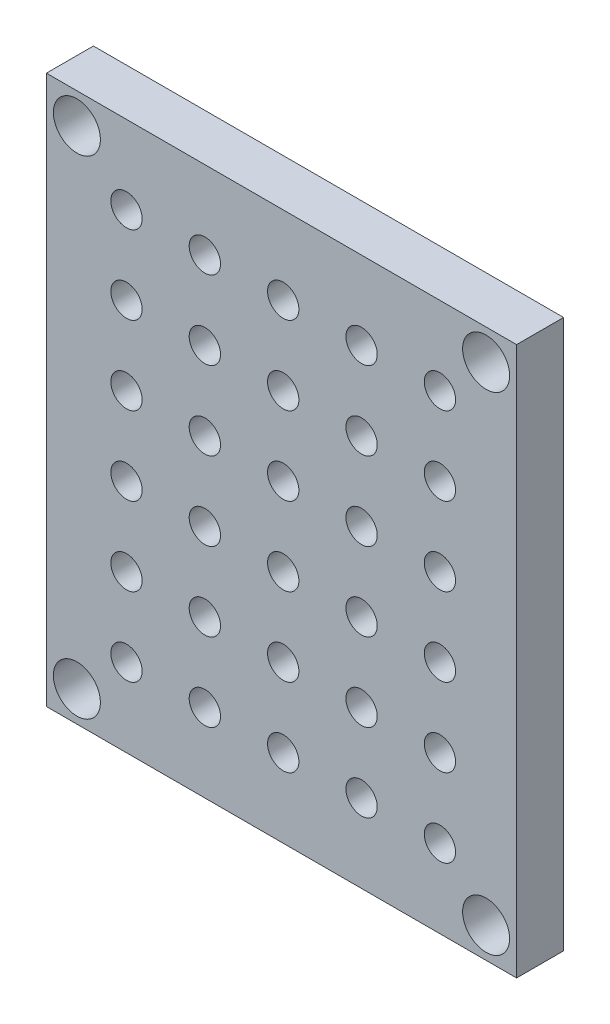
from build123d import *

# Parameters (mm, degrees)
BOSS_EXTRU_4_DEPTH      = 2
ESQUISSE9_W             = 30
ESQUISSE9_H             = 35
BOSS_EXTRU_5_DEPTH      = 3
ESQUISSE7_R             = 1.5
ENL_V_MAT_EXTRU_8_DEPTH = 6
ESQUISSE10_R            = 1
ENL_V_MAT_EXTRU_9_DEPTH = 6


with BuildPart() as part:
    # Esquisse8 → Boss.-Extru.4 (new body)
    with BuildSketch(Plane.XY):
        Polygon((-9.5, 15), (9.5, 15), (12.5, 12), (12.5, -12), (9.5, -15), (-9.5, -15), (-12.5, -12), (-12.5, 12), align=None)
    extrude(amount=-BOSS_EXTRU_4_DEPTH)

    # Esquisse9 → Boss.-Extru.5 (add)
    with BuildSketch(Plane.XY):
        Rectangle(ESQUISSE9_W, ESQUISSE9_H)
    extrude(amount=BOSS_EXTRU_5_DEPTH)

    # Esquisse7 → Enlèv. mat.-Extru.8 (cut, through all)
    with BuildSketch(Plane.XY.offset(3)):
        with Locations((-13.055456352, 15.555456352)):
            Circle(ESQUISSE7_R)
        with Locations((-13.055456352, -15.555456352)):
            Circle(ESQUISSE7_R)
        with Locations((13.055456352, -15.555456352)):
            Circle(ESQUISSE7_R)
        with Locations((13.055456352, 15.555456352)):
            Circle(ESQUISSE7_R)
    extrude(amount=-ENL_V_MAT_EXTRU_8_DEPTH, mode=Mode.SUBTRACT)

    # Esquisse10 → Enlèv. mat.-Extru.9 (cut, through all)
    with BuildSketch(Plane.XY.offset(3)):
        with Locations((-9.890325409, 12.506661491)):
            Circle(ESQUISSE10_R)
        with Locations((-4.890325409, 12.506661491)):
            Circle(ESQUISSE10_R)
        with Locations((0.109674591, 12.506661491)):
            Circle(ESQUISSE10_R)
        with Locations((5.109674591, 12.506661491)):
            Circle(ESQUISSE10_R)
        with Locations((10.109674591, 12.506661491)):
            Circle(ESQUISSE10_R)
        with Locations((-4.890325409, 7.506661491)):
            Circle(ESQUISSE10_R)
        with Locations((0.109674591, 7.506661491)):
            Circle(ESQUISSE10_R)
        with Locations((5.109674591, 7.506661491)):
            Circle(ESQUISSE10_R)
        with Locations((10.109674591, 7.506661491)):
            Circle(ESQUISSE10_R)
        with Locations((-4.890325409, 2.506661491)):
            Circle(ESQUISSE10_R)
        with Locations((0.109674591, 2.506661491)):
            Circle(ESQUISSE10_R)
        with Locations((5.109674591, 2.506661491)):
            Circle(ESQUISSE10_R)
        with Locations((10.109674591, 2.506661491)):
            Circle(ESQUISSE10_R)
        with Locations((-4.890325409, -2.493338509)):
            Circle(ESQUISSE10_R)
        with Locations((0.109674591, -2.493338509)):
            Circle(ESQUISSE10_R)
        with Locations((5.109674591, -2.493338509)):
            Circle(ESQUISSE10_R)
        with Locations((10.109674591, -2.493338509)):
            Circle(ESQUISSE10_R)
        with Locations((-4.890325409, -7.493338509)):
            Circle(ESQUISSE10_R)
        with Locations((0.109674591, -7.493338509)):
            Circle(ESQUISSE10_R)
        with Locations((5.109674591, -7.493338509)):
            Circle(ESQUISSE10_R)
        with Locations((10.109674591, -7.493338509)):
            Circle(ESQUISSE10_R)
        with Locations((-4.890325409, -12.493338509)):
            Circle(ESQUISSE10_R)
        with Locations((0.109674591, -12.493338509)):
            Circle(ESQUISSE10_R)
        with Locations((5.109674591, -12.493338509)):
            Circle(ESQUISSE10_R)
        with Locations((10.109674591, -12.493338509)):
            Circle(ESQUISSE10_R)
        with Locations((-9.890325409, 7.506661491)):
            Circle(ESQUISSE10_R)
        with Locations((-9.890325409, 2.506661491)):
            Circle(ESQUISSE10_R)
        with Locations((-9.890325409, -2.493338509)):
            Circle(ESQUISSE10_R)
        with Locations((-9.890325409, -7.493338509)):
            Circle(ESQUISSE10_R)
        with Locations((-9.890325409, -12.493338509)):
            Circle(ESQUISSE10_R)
    extrude(amount=-ENL_V_MAT_EXTRU_9_DEPTH, mode=Mode.SUBTRACT)


solid = part.part
